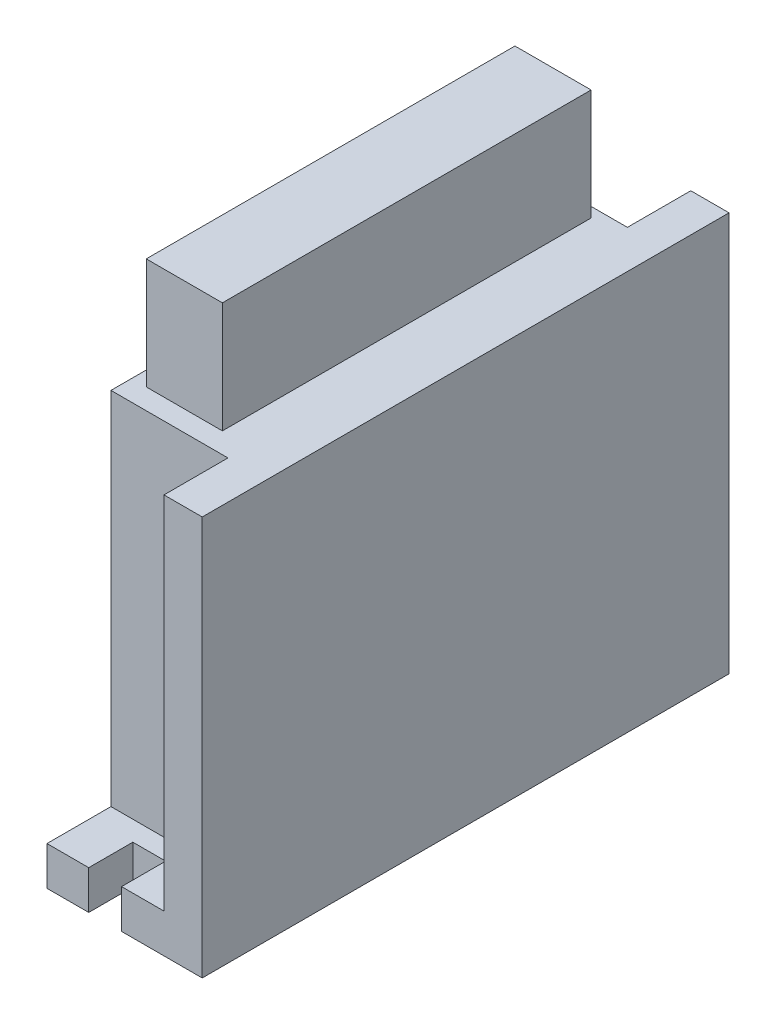
from build123d import *

# Parameters (mm, degrees)
SKETCH1_W           = 28
SKETCH1_H           = 95
BOSS_EXTRUDE1_DEPTH = 72
SKETCH2_W           = 13.730616592
SKETCH2_H           = 66.486096825
BOSS_EXTRUDE2_DEPTH = 20
SKETCH3_W           = 21.103215472
SKETCH3_H           = 11.539971669
SKETCH3_H_2         = 11.43433275
CUT_EXTRUDE1_DEPTH  = 65
SKETCH4_W           = 5.921037469
SKETCH4_H           = 7.955384718
CUT_EXTRUDE2_DEPTH  = 65


with BuildPart() as part:
    # Sketch1 → Boss-Extrude1 (new body)
    with BuildSketch(Plane(origin=(0, 0, 0), x_dir=(1, 0, 0), z_dir=(0, 1, 0))):
        with Locations((5.145873321, -3.829174664)):
            Rectangle(SKETCH1_W, SKETCH1_H)
    extrude(amount=BOSS_EXTRUDE1_DEPTH)

    # Sketch2 → Boss-Extrude2 (add)
    with BuildSketch(Plane(origin=(0, 72, 0), x_dir=(1, 0, 0), z_dir=(0, 1, 0))):
        with Locations((0.655068483, -2.824577048)):
            Rectangle(SKETCH2_W, SKETCH2_H)
    extrude(amount=BOSS_EXTRUDE2_DEPTH)

    # Sketch3 → Cut-Extrude1 (cut)
    with BuildSketch(Plane(origin=(0, 72, 0), x_dir=(1, 0, 0), z_dir=(0, 1, 0))):
        with Locations((1.697481057, -45.55918883)):
            Rectangle(SKETCH3_W, SKETCH3_H)
        with Locations((1.697481057, 37.953658961)):
            Rectangle(SKETCH3_W, SKETCH3_H_2)
    extrude(amount=-CUT_EXTRUDE1_DEPTH, mode=Mode.SUBTRACT)

    # Sketch4 → Cut-Extrude2 (cut)
    with BuildSketch(Plane(origin=(0, 7, 0), x_dir=(1, 0, 0), z_dir=(0, 1, 0))):
        with Locations((1.637392249, -47.351482305)):
            Rectangle(SKETCH4_W, SKETCH4_H)
        with Locations((1.637392249, 39.693132977)):
            Rectangle(SKETCH4_W, SKETCH4_H)
    extrude(amount=-CUT_EXTRUDE2_DEPTH, mode=Mode.SUBTRACT)


solid = part.part
